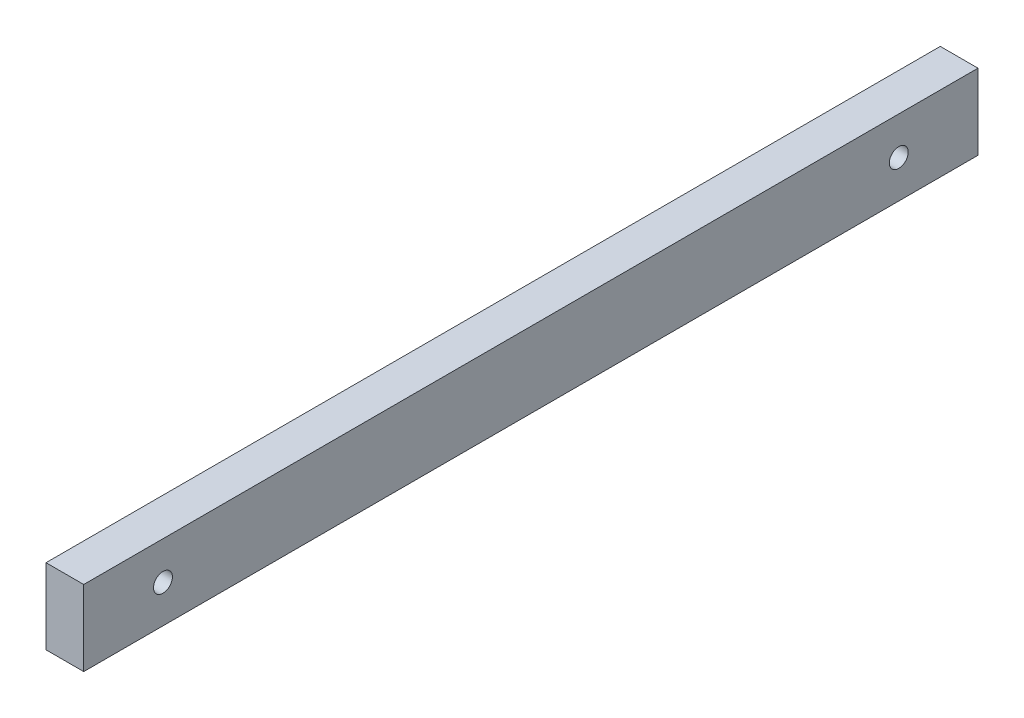
from build123d import *

# Parameters (mm, degrees)
SKETCH1_W           = 10
SKETCH1_H           = 237
BOSS_EXTRUDE2_DEPTH = 20
SKETCH4_R           = 2.5
CUT_EXTRUDE2_DEPTH  = 10


with BuildPart() as part:
    # Sketch1 → Boss-Extrude2 (new body)
    with BuildSketch(Plane(origin=(0, 0, 0), x_dir=(1, 0, 0), z_dir=(0, 1, 0))):
        Rectangle(SKETCH1_W, SKETCH1_H)
    extrude(amount=BOSS_EXTRUDE2_DEPTH)

    # Sketch4 → Cut-Extrude2 (cut)
    with BuildSketch(Plane(origin=(5, 0, 0), x_dir=(0, 0, -1), z_dir=(1, 0, 0))):
        with Locations((-97.5, 10)):
            Circle(SKETCH4_R)
        with Locations((97.5, 10)):
            Circle(SKETCH4_R)
    extrude(amount=-CUT_EXTRUDE2_DEPTH, mode=Mode.SUBTRACT)


solid = part.part
